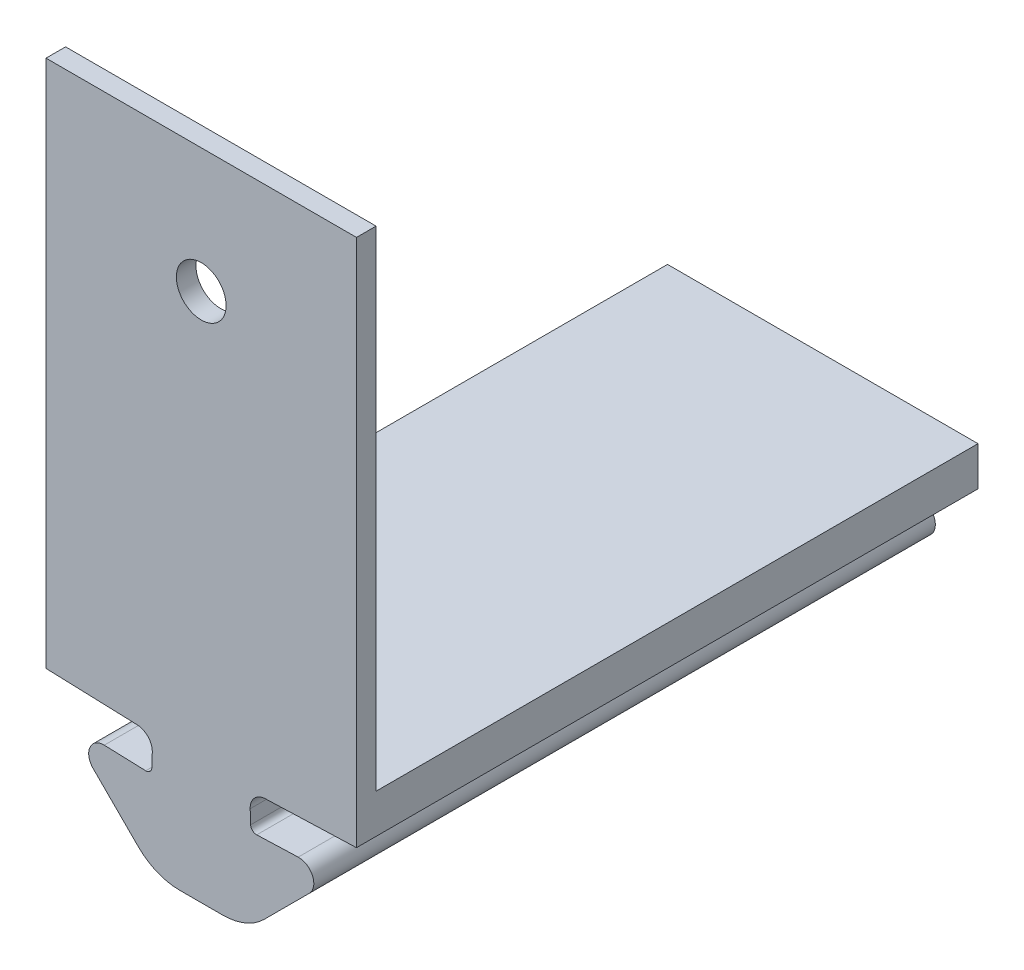
from build123d import *

# Parameters (mm, degrees)
BOSS_EXTRUDE1_DEPTH = 31.75
SKETCH19_W          = 15.860402013
SKETCH19_H          = 31.75
BOSS_EXTRUDE7_DEPTH = 2
SKETCH23_W          = 15.860402013
SKETCH23_H          = 1
BOSS_EXTRUDE8_DEPTH = 25
SKETCH24_R          = 1.27
CUT_EXTRUDE1_DEPTH  = 2.54


with BuildPart() as part:
    # Sketch2 → Boss-Extrude1 (new body)
    with BuildSketch(Plane.XY):
        with BuildLine():
            Line((-50.375618534, 45.609862895), (-50.351188886, 46.309436474))
            ThreePointArc((-50.351188886, 46.309436474), (-50.565618587, 46.88295476), (-51.12278195, 47.136868733))
            Line((-51.12278195, 47.136868733), (-55.780902554, 47.299533889))
            Line((-55.780902554, 47.299533889), (-47.850701548, 47.299533889))
            Line((-47.850701548, 47.299533889), (-47.850701548, 40.900752235))
            Line((-47.850701548, 40.900752235), (-48.952946324, 40.900752235))
            ThreePointArc((-48.952946324, 40.900752235), (-50.100996621, 41.129113637), (-51.074266668, 41.779431891))
            Line((-51.074266668, 41.779431891), (-53.375146928, 44.080312152))
            ThreePointArc((-53.375146928, 44.080312152), (-53.536830204, 44.931922499), (-52.803734096, 45.394471696))
            Line((-52.803734096, 45.394471696), (-50.685905631, 45.320515496))
            ThreePointArc((-50.685905631, 45.320515496), (-50.470836274, 45.400926634), (-50.375618534, 45.609862895))
        make_face()
    boss_extrude1 = extrude(amount=BOSS_EXTRUDE1_DEPTH)

    # Mirror2: Boss-Extrude1 across plane
    add(boss_extrude1.mirror(Plane(origin=(-47.850701548, 40.900752235, 31.75), x_dir=(0, 0, 1), z_dir=(-1, 0, 0))))

    # Sketch19 → Boss-Extrude7 (add)
    with BuildSketch(Plane(origin=(0, 47.299533889, 0), x_dir=(1, 0, 0), z_dir=(0, 1, 0))):
        with Locations((-47.850701548, -15.875)):
            Rectangle(SKETCH19_W, SKETCH19_H)
    extrude(amount=BOSS_EXTRUDE7_DEPTH)

    # Sketch23 → Boss-Extrude8 (add)
    with BuildSketch(Plane(origin=(0, 49.299533889, 0), x_dir=(1, 0, 0), z_dir=(0, 1, 0))):
        with Locations((-47.850701548, -31.25)):
            Rectangle(SKETCH23_W, SKETCH23_H)
    extrude(amount=BOSS_EXTRUDE8_DEPTH)

    # Sketch24 → Cut-Extrude1 (cut)
    with BuildSketch(Plane(origin=(0, 0, 30.75), x_dir=(-1, 0, 0), z_dir=(0, 0, -1))):
        with Locations((47.850701548, 67.949533889)):
            Circle(SKETCH24_R)
    extrude(amount=-CUT_EXTRUDE1_DEPTH, mode=Mode.SUBTRACT)


solid = part.part
